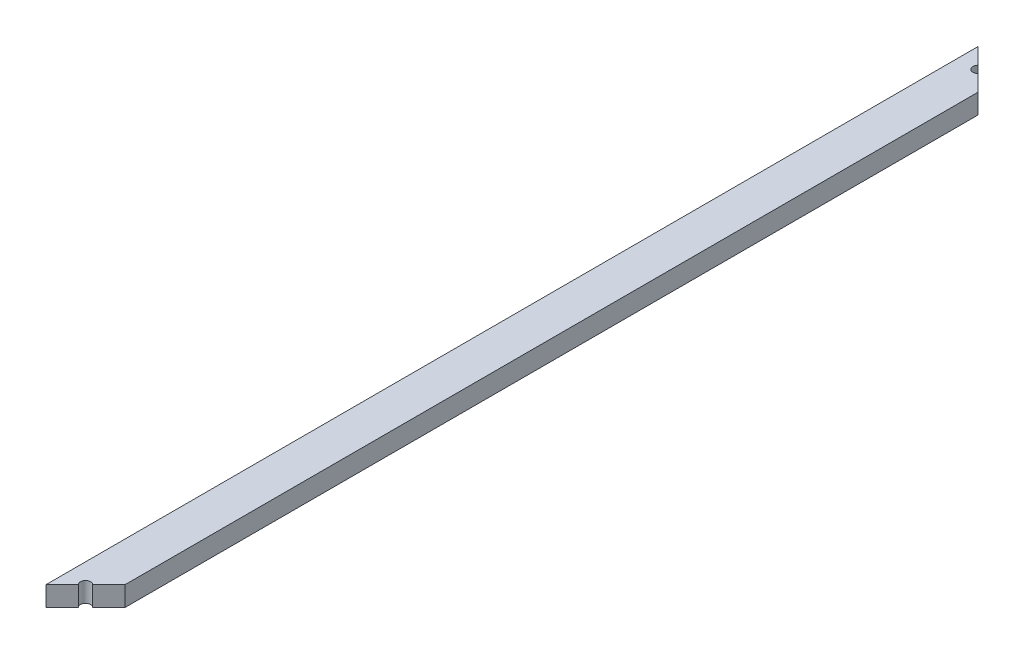
from build123d import *

# Parameters (mm, degrees)
SKETCH1_W           = 14
SKETCH1_H           = 7
BOSS_EXTRUDE1_DEPTH = 330
CUT_EXTRUDE1_DEPTH  = 8
CUT_EXTRUDE2_DEPTH  = 8


with BuildPart() as part:
    # Sketch1 → Boss-Extrude1 (new body)
    with BuildSketch(Plane.XY):
        with Locations((7, 3.5)):
            Rectangle(SKETCH1_W, SKETCH1_H)
    extrude(amount=BOSS_EXTRUDE1_DEPTH)

    # Sketch2 → Cut-Extrude1 (cut, through all)
    with BuildSketch(Plane(origin=(0, 7, 0), x_dir=(1, 0, 0), z_dir=(0, 1, 0))):
        Polygon((0, 0), (14, -14), (14, 0), align=None)
        Polygon((14, -330), (0, -330), (14, -316), align=None)
    extrude(amount=-CUT_EXTRUDE1_DEPTH, mode=Mode.SUBTRACT)

    # Sketch3 → Cut-Extrude2 (cut, through all)
    with BuildSketch(Plane(origin=(0, 7, 0), x_dir=(1, 0, 0), z_dir=(0, 1, 0))):
        with BuildLine():
            Line((5.727207794, -5.727207794), (8.272792206, -8.272792206))
            ThreePointArc((8.272792206, -8.272792206), (5.727207794, -8.272792206), (5.727207794, -5.727207794))
        make_face()
        with BuildLine():
            Line((5.727207794, -324.272792206), (8.272792206, -321.727207794))
            ThreePointArc((8.272792206, -321.727207794), (5.727207794, -321.727207794), (5.727207794, -324.272792206))
        make_face()
    extrude(amount=-CUT_EXTRUDE2_DEPTH, mode=Mode.SUBTRACT)


solid = part.part
